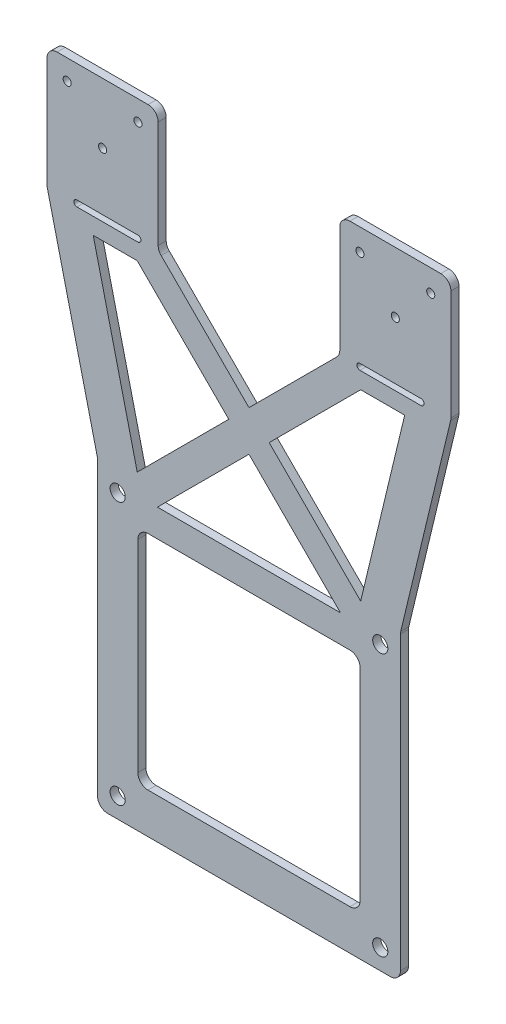
from build123d import *

# Parameters (mm, degrees)
SKETCH1_R           = 1.875
SKETCH1_R_2         = 1
BOSS_EXTRUDE2_DEPTH = 2


with BuildPart() as part:
    # Sketch1 → Boss-Extrude2 (new body)
    with BuildSketch(Plane.XY):
        with BuildLine():
            Line((-35, -264.548366883), (35, -264.548366883))
            ThreePointArc((35, -264.548366883), (36.767766953, -263.816133836), (37.5, -262.048366883))
            Line((37.5, -262.048366883), (37.5, -189.844720828))
            ThreePointArc((37.5, -189.844720828), (37.517382153, -189.550427391), (37.569286901, -189.260226318))
            Line((37.569286901, -189.260226318), (49.928636869, -137.861909768))
            ThreePointArc((49.928636869, -137.861909768), (49.980541617, -137.571708695), (49.99792377, -137.277415258))
            Line((49.99792377, -137.277415258), (49.99792377, -110.073769203))
            ThreePointArc((49.99792377, -110.073769203), (49.265690723, -108.30600225), (47.49792377, -107.573769203))
            Line((47.49792377, -107.573769203), (24.98250936, -107.573769203))
            ThreePointArc((24.98250936, -107.573769203), (23.214742407, -108.30600225), (22.48250936, -110.073769203))
            Line((22.48250936, -110.073769203), (22.48250936, -136.538235297))
            ThreePointArc((22.48250936, -136.538235297), (22.292208191, -137.494943878), (21.750276313, -138.30600225))
            Line((21.750276313, -138.30600225), (0.000286917, -160.055991645))
            Line((0.000286917, -160.055991645), (-21.749702478, -138.30600225))
            ThreePointArc((-21.749702478, -138.30600225), (-22.291634357, -137.494943878), (-22.481935525, -136.538235297))
            Line((-22.481935525, -136.538235297), (-22.481935525, -110.073769203))
            ThreePointArc((-22.481935525, -110.073769203), (-23.214168572, -108.30600225), (-24.981935525, -107.573769203))
            Line((-24.981935525, -107.573769203), (-47.49792377, -107.573769203))
            ThreePointArc((-47.49792377, -107.573769203), (-49.265690723, -108.30600225), (-49.99792377, -110.073769203))
            Line((-49.99792377, -110.073769203), (-49.99792377, -137.277415258))
            ThreePointArc((-49.99792377, -137.277415258), (-49.980541617, -137.571708695), (-49.928636869, -137.861909768))
            Line((-49.928636869, -137.861909768), (-37.5, -189.548366883))
            Line((-37.5, -189.548366883), (-37.5, -262.048366883))
            ThreePointArc((-37.5, -262.048366883), (-36.767766953, -263.816133836), (-35, -264.548366883))
        make_face()
        with Locations((32.5, -259.548366883)):
            Circle(SKETCH1_R, mode=Mode.SUBTRACT)
        with Locations((-32.5, -259.548366883)):
            Circle(SKETCH1_R, mode=Mode.SUBTRACT)
        with Locations((-32.5, -194.548366883)):
            Circle(SKETCH1_R, mode=Mode.SUBTRACT)
        with Locations((32.5, -194.548366883)):
            Circle(SKETCH1_R, mode=Mode.SUBTRACT)
        with Locations((-45, -112.573769203)):
            Circle(SKETCH1_R_2, mode=Mode.SUBTRACT)
        with Locations((-27.481935525, -112.573769203)):
            Circle(SKETCH1_R_2, mode=Mode.SUBTRACT)
        with Locations((27.481935525, -113.029421113)):
            Circle(SKETCH1_R_2, mode=Mode.SUBTRACT)
        with Locations((45, -113.029421113)):
            Circle(SKETCH1_R_2, mode=Mode.SUBTRACT)
        with Locations((-36.239929648, -122.573769203)):
            Circle(SKETCH1_R_2, mode=Mode.SUBTRACT)
        with Locations((36.239929648, -122.573769203)):
            Circle(SKETCH1_R_2, mode=Mode.SUBTRACT)
        Polygon((-27.65637254, -187.712651103), (-38.552510863, -142.399332188), (-27.65637254, -142.399332188), (-4.999713083, -165.055991645), align=None, mode=Mode.SUBTRACT)
        Polygon((38.552510863, -142.399332188), (27.656946375, -187.712651103), (5.000286917, -165.055991645), (27.65637254, -142.399332188), align=None, mode=Mode.SUBTRACT)
        with BuildLine():
            Line((-27.5, -204.548366883), (-27.5, -249.548366883))
            Line((-27.5, -249.548366883), (-27.5, -252.048366883))
            ThreePointArc((-27.5, -252.048366883), (-26.767766953, -253.816133836), (-25, -254.548366883))
            Line((-25, -254.548366883), (-16.464466094, -254.548366883))
            Line((-16.464466094, -254.548366883), (16.464466094, -254.548366883))
            Line((16.464466094, -254.548366883), (25, -254.548366883))
            ThreePointArc((25, -254.548366883), (26.767766953, -253.816133836), (27.5, -252.048366883))
            Line((27.5, -252.048366883), (27.5, -249.548366883))
            Line((27.5, -249.548366883), (27.5, -204.548366883))
            Line((27.5, -204.548366883), (27.5, -202.048366883))
            ThreePointArc((27.5, -202.048366883), (26.767766953, -200.28059993), (25, -199.548366883))
            Line((25, -199.548366883), (22.5, -199.548366883))
            Line((22.5, -199.548366883), (-22.5, -199.548366883))
            Line((-22.5, -199.548366883), (-25, -199.548366883))
            ThreePointArc((-25, -199.548366883), (-26.767766953, -200.28059993), (-27.5, -202.048366883))
            Line((-27.5, -202.048366883), (-27.5, -204.548366883))
        make_face(mode=Mode.SUBTRACT)
        Polygon((-22.65637254, -192.712651103), (22.656946375, -192.712651103), (0.000286917, -170.055991645), align=None, mode=Mode.SUBTRACT)
        with BuildLine():
            Line((-42.587811549, -136.823769203), (-27.481935525, -136.823769203))
            ThreePointArc((-27.481935525, -136.823769203), (-26.731935525, -137.573769203), (-27.481935525, -138.323769203))
            Line((-27.481935525, -138.323769203), (-42.587811549, -138.323769203))
            ThreePointArc((-42.587811549, -138.323769203), (-43.337811549, -137.573769203), (-42.587811549, -136.823769203))
        make_face(mode=Mode.SUBTRACT)
        with BuildLine():
            Line((42.587811549, -136.823769203), (27.481935525, -136.823769203))
            ThreePointArc((27.481935525, -136.823769203), (26.731935525, -137.573769203), (27.481935525, -138.323769203))
            Line((27.481935525, -138.323769203), (42.587811549, -138.323769203))
            ThreePointArc((42.587811549, -138.323769203), (43.337811549, -137.573769203), (42.587811549, -136.823769203))
        make_face(mode=Mode.SUBTRACT)
    extrude(amount=BOSS_EXTRUDE2_DEPTH)


solid = part.part
